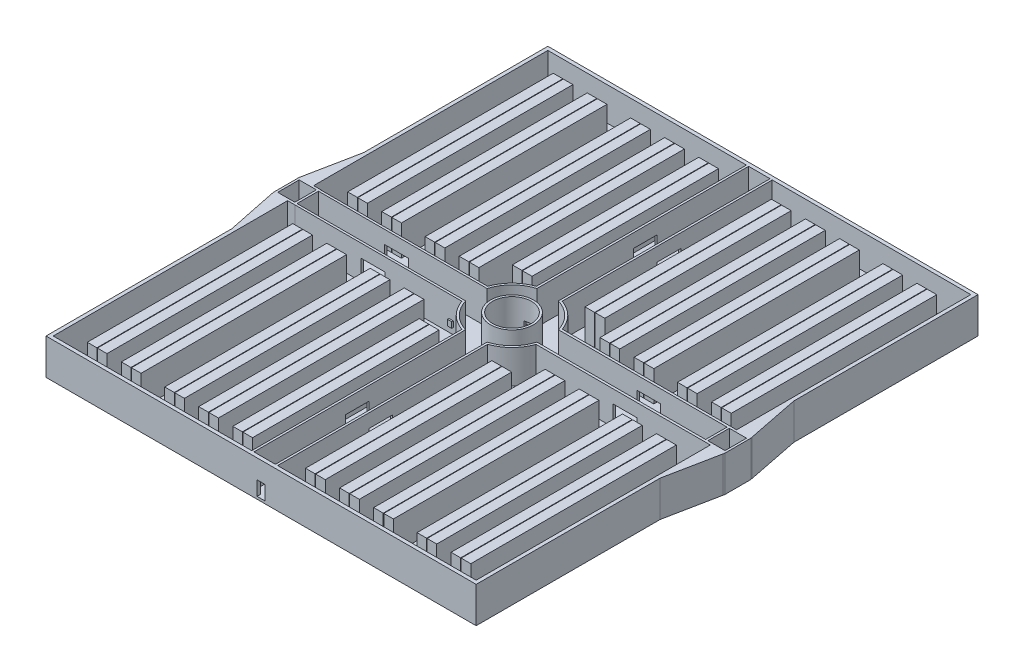
from build123d import *

# Parameters (mm, degrees)
SKETCH2_W                 = 60000
SKETCH2_H                 = 70000
BOSS_EXTRUDE1_DEPTH       = 350
SKETCH3_R                 = 3000
CUT_EXTRUDE1_DEPTH        = 1
CUT_EXTRUDE1_DEPTH_BACK   = 351
BOSS_EXTRUDE2_DEPTH       = 4650
CUT_EXTRUDE2_START        = -31801
CUT_EXTRUDE2_DEPTH        = 60002
CUT_EXTRUDE3_START        = -36801
CUT_EXTRUDE3_DEPTH        = 70002
SKETCH9_W                 = 60000
SKETCH9_H                 = 70000
SKETCH9_W_2               = 59000
SKETCH9_H_2               = 69000
BOSS_EXTRUDE3_DEPTH       = 4650
CUT_EXTRUDE4_DEPTH        = 1
CUT_EXTRUDE4_DEPTH_BACK   = 70001
SKETCH12_W                = 1337.685506768
SKETCH12_H                = 28664.780813437
SKETCH12_W_2              = 1337.314493232
BOSS_EXTRUDE5_DEPTH       = 4270
SKETCH13_R                = 3000
SKETCH13_R_2              = 2700
BOSS_EXTRUDE6_DEPTH       = 5000
BOSS_EXTRUDE6_DEPTH_BACK  = 1000
CUT_EXTRUDE6_DEPTH        = 60000
SKETCH16_W                = 1340
SKETCH16_H                = 26000
BOSS_EXTRUDE7_DEPTH       = 4270
MIRROR4_COPY_1_SKETCH_W   = 1337.685506768
MIRROR4_COPY_1_SKETCH_H   = 28664.780813437
MIRROR4_COPY_1_SKETCH_W_2 = 1337.314493232
MIRROR4_COPY_1_DEPTH      = 4270
MIRROR5_COPY_1_SKETCH_W   = 1337.685506768
MIRROR5_COPY_1_SKETCH_H   = 28664.780813437
MIRROR5_COPY_1_SKETCH_W_2 = 1337.314493232
MIRROR5_COPY_1_DEPTH      = 4270
MIRROR5_COPY_2_SKETCH_W   = 1340
MIRROR5_COPY_2_SKETCH_H   = 26000
MIRROR5_COPY_2_DEPTH      = 4270
MIRROR5_COPY_3_SKETCH_W   = 1337.685506768
MIRROR5_COPY_3_SKETCH_H   = 28664.780813437
MIRROR5_COPY_3_SKETCH_W_2 = 1337.314493232
MIRROR5_COPY_3_DEPTH      = 4270
MIRROR5_COPY_4_SKETCH_W   = 1337.685506768
MIRROR5_COPY_4_SKETCH_H   = 28664.780813437
MIRROR5_COPY_4_SKETCH_W_2 = 1337.314493232
MIRROR5_COPY_4_DEPTH      = 4270
BOSS_EXTRUDE12_START      = -350
BOSS_EXTRUDE12_DEPTH      = 5000
SKETCH26_W                = 600
SKETCH26_H                = 800
BOSS_EXTRUDE14_DEPTH      = 220
MIRROR15_COPY_1_SKETCH_W  = 600
MIRROR15_COPY_1_SKETCH_H  = 800
MIRROR15_COPY_1_DEPTH     = 220
MIRROR15_COPY_2_SKETCH_W  = 600
MIRROR15_COPY_2_SKETCH_H  = 800
MIRROR15_COPY_2_DEPTH     = 220
SKETCH20_W                = 2400
SKETCH20_H                = 3000
CUT_EXTRUDE7_DEPTH        = 4650
CUT_EXTRUDE9_DEPTH        = 400


with BuildPart() as part:
    # Sketch2 → Boss-Extrude1 (new body)
    with BuildSketch(Plane(origin=(0, 0, 0), x_dir=(1, 0, 0), z_dir=(0, 1, 0))):
        Rectangle(SKETCH2_W, SKETCH2_H)
    extrude(amount=BOSS_EXTRUDE1_DEPTH)

    # Sketch3 → Cut-Extrude1 (cut, two sides)
    with BuildSketch(Plane(origin=(0, 350, 0), x_dir=(1, 0, 0), z_dir=(0, 1, 0))) as cut_extrude1_sk:
        Circle(SKETCH3_R)
    extrude(amount=CUT_EXTRUDE1_DEPTH, mode=Mode.SUBTRACT)
    extrude(cut_extrude1_sk.sketch, amount=-CUT_EXTRUDE1_DEPTH_BACK, mode=Mode.SUBTRACT)

    # Sketch4 → Boss-Extrude2 (add)
    with BuildSketch(Plane(origin=(0, 350, 0), x_dir=(1, 0, 0), z_dir=(0, 1, 0))):
        with BuildLine():
            Line((-30000, 1495.711965542), (-30000, 1795.711965542))
            Line((-30000, 1795.711965542), (-5198.597747163, 1795.711965542))
            ThreePointArc((-5198.597747163, 1795.711965542), (-3890.6911404, 3887.48279096), (-1800, 5197.114584075))
            Line((-1800, 5197.114584075), (-1800, 35000))
            Line((-1800, 35000), (-1500, 35000))
            Line((-1500, 35000), (-1500, 4978.955713802))
            ThreePointArc((-1500, 4978.955713802), (-3678.538071342, 3675.371771357), (-4980.245547775, 1495.711965542))
            Line((-4980.245547775, 1495.711965542), (-5292.716289027, 1495.711965542))
            Line((-5292.716289027, 1495.711965542), (-30000, 1495.711965542))
        make_face()
        with BuildLine():
            Line((-30000, -1500), (-4978.955713802, -1500))
            ThreePointArc((-4978.955713802, -1500), (-3676.95526217, -3676.95526217), (-1500, -4978.955713802))
            Line((-1500, -4978.955713802), (-1500, -35000))
            Line((-1500, -35000), (-1800, -35000))
            Line((-1800, -35000), (-1800, -5197.114584075))
            ThreePointArc((-1800, -5197.114584075), (-3889.087296526, -3889.087296526), (-5197.114584075, -1800))
            Line((-5197.114584075, -1800), (-30000, -1800))
            Line((-30000, -1800), (-30000, -1500))
        make_face()
        with BuildLine():
            Line((30000, 1495.711965542), (30000, 1830.438373126))
            Line((30000, 1830.438373126), (5186.472342758, 1830.438373126))
            ThreePointArc((5186.472342758, 1830.438373126), (3877.670193089, 3900.470981001), (1800, 5197.114584075))
            Line((1800, 5197.114584075), (1800, 35000))
            Line((1800, 35000), (1500, 35000))
            Line((1500, 35000), (1500, 4978.955713802))
            ThreePointArc((1500, 4978.955713802), (3678.538071342, 3675.371771357), (4980.245547775, 1495.711965542))
            Line((4980.245547775, 1495.711965542), (30000, 1495.711965542))
        make_face()
        with BuildLine():
            Line((4978.955713802, -1500), (30000, -1500))
            Line((30000, -1500), (30000, -1800))
            Line((30000, -1800), (5197.114584075, -1800))
            ThreePointArc((5197.114584075, -1800), (3889.087296526, -3889.087296526), (1800, -5197.114584075))
            Line((1800, -5197.114584075), (1800, -35000))
            Line((1800, -35000), (1500, -35000))
            Line((1500, -35000), (1500, -4978.955713802))
            ThreePointArc((1500, -4978.955713802), (3676.95526217, -3676.95526217), (4978.955713802, -1500))
        make_face()
    extrude(amount=BOSS_EXTRUDE2_DEPTH)

    # Sketch6 → Cut-Extrude2 (cut)
    with BuildSketch(Plane.ZY.offset(1800).offset(CUT_EXTRUDE2_START)):
        Polygon((20098.557292037, 350), (21748.557292037, 350), (21748.557292037, 3100), (20098.557292037, 3100), (18448.557292037, 3100), (18448.557292037, 350), align=None)
    cut_extrude2 = extrude(amount=CUT_EXTRUDE2_DEPTH, mode=Mode.SUBTRACT)

    # Mirror1: Cut-Extrude2 across plane
    add(cut_extrude2.mirror(Plane(origin=(0, 0, 0), x_dir=(1, 0, 0), z_dir=(0, 0, -1))), mode=Mode.SUBTRACT)

    # Sketch7 → Cut-Extrude3 (cut)
    with BuildSketch(Plane.XY.offset(1800).offset(CUT_EXTRUDE3_START)):
        Polygon((-17598.557292037, 350), (-15948.557292037, 350), (-15948.557292037, 3170.045761237), (-17598.557292037, 3170.045761237), (-19248.557292037, 3170.045761237), (-19248.557292037, 350), align=None)
    cut_extrude3 = extrude(amount=CUT_EXTRUDE3_DEPTH, mode=Mode.SUBTRACT)

    # Mirror2: Cut-Extrude3 across plane
    add(cut_extrude3.mirror(Plane.ZY), mode=Mode.SUBTRACT)

    # Sketch9 → Boss-Extrude3 (add)
    with BuildSketch(Plane(origin=(0, 350, 0), x_dir=(1, 0, 0), z_dir=(0, 1, 0))):
        Rectangle(SKETCH9_W, SKETCH9_H)
        Rectangle(SKETCH9_W_2, SKETCH9_H_2, mode=Mode.SUBTRACT)
    extrude(amount=BOSS_EXTRUDE3_DEPTH)

    # Sketch11 → Cut-Extrude4 (cut, two sides)
    with BuildSketch(Plane.XY.offset(35000)) as cut_extrude4_sk:
        Polygon((550, 2345.832597599), (550, 2000), (550, 350), (-550, 350), (-550, 2000), (-550, 2345.832597599), align=None)
    extrude(amount=CUT_EXTRUDE4_DEPTH, mode=Mode.SUBTRACT)
    extrude(cut_extrude4_sk.sketch, amount=-CUT_EXTRUDE4_DEPTH_BACK, mode=Mode.SUBTRACT)

    # Sketch12 → Boss-Extrude5 (add)
    with BuildSketch(Plane(origin=(0, 350, 0), x_dir=(1, 0, 0), z_dir=(0, 1, 0))):
        with Locations((21329.714538653, 18162.828779845)):
            Rectangle(SKETCH12_W, SKETCH12_H)
        with Locations((19917.214538653, 18162.828779845)):
            Rectangle(SKETCH12_W_2, SKETCH12_H)
        Polygon((25411.057292037, 3830.438373126), (25411.057292037, 32495.219186563), (26748.557292037, 32495.219186563), (26748.557292037, 18184.780561825), (26748.557292037, 3830.438373126), align=None)
        Polygon((25336.057292037, 3830.438373126), (25336.057292037, 32495.219186563), (25160, 32495.219186563), (25090, 32495.219186563), (23998.557292037, 32495.219186563), (23998.557292037, 18165.219186563), (23998.557292037, 3830.438373126), (25090, 3830.438373126), (25102.109097724, 3830.438373126), (25160, 3830.438373126), align=None)
    boss_extrude5 = extrude(amount=BOSS_EXTRUDE5_DEPTH)

    # Mirror3: Boss-Extrude5 across plane
    add(boss_extrude5.mirror(Plane.ZY.offset(-17598.557292037)))

    # Sketch13 → Boss-Extrude6 (add, two sides)
    with BuildSketch(Plane(origin=(0, 350, 0), x_dir=(1, 0, 0), z_dir=(0, 1, 0))) as boss_extrude6_sk:
        Circle(SKETCH13_R)
        Circle(SKETCH13_R_2, mode=Mode.SUBTRACT)
    extrude(amount=BOSS_EXTRUDE6_DEPTH)
    extrude(boss_extrude6_sk.sketch, amount=-BOSS_EXTRUDE6_DEPTH_BACK)

    # Sketch15 → Cut-Extrude6 (cut)
    with BuildSketch(Plane(origin=(0, 0, 34500), x_dir=(-1, 0, 0), z_dir=(0, 0, -1))):
        Polygon((0, 350), (900, 350), (900, 2345.832597599), (900, 2600), (0, 2600), (-900, 2600), (-900, 350), align=None)
    extrude(amount=CUT_EXTRUDE6_DEPTH, mode=Mode.SUBTRACT)

    # Sketch16 → Boss-Extrude7 (add)
    with BuildSketch(Plane(origin=(0, 350, 0), x_dir=(1, 0, 0), z_dir=(0, 1, 0))):
        with Locations((5778.557292037, 19495.219186563)):
            Rectangle(SKETCH16_W, SKETCH16_H)
        with Locations((4363.557292037, 19495.219186563)):
            Rectangle(SKETCH16_W, SKETCH16_H)
    boss_extrude7 = extrude(amount=BOSS_EXTRUDE7_DEPTH)

    # Mirror4: Boss-Extrude7, Boss-Extrude5 across plane
    add(boss_extrude7.mirror(Plane.ZY))
    add(boss_extrude5.mirror(Plane.ZY))

    # Mirror4 copy 1 sketch → Mirror4 copy 1 (add)
    with BuildSketch(Plane(origin=(-35197.114584075, 350, 0), x_dir=(1, 0, 0), z_dir=(0, 1, 0))):
        with Locations((21329.714538653, 18162.828779845)):
            Rectangle(MIRROR4_COPY_1_SKETCH_W, MIRROR4_COPY_1_SKETCH_H)
        with Locations((19917.214538653, 18162.828779845)):
            Rectangle(MIRROR4_COPY_1_SKETCH_W_2, MIRROR4_COPY_1_SKETCH_H)
        Polygon((25411.057292037, 3830.438373126), (25411.057292037, 32495.219186563), (26748.557292037, 32495.219186563), (26748.557292037, 18184.780561825), (26748.557292037, 3830.438373126), align=None)
        Polygon((25336.057292037, 3830.438373126), (25336.057292037, 32495.219186563), (25160, 32495.219186563), (25090, 32495.219186563), (23998.557292037, 32495.219186563), (23998.557292037, 18165.219186563), (23998.557292037, 3830.438373126), (25090, 3830.438373126), (25102.109097724, 3830.438373126), (25160, 3830.438373126), align=None)
    extrude(amount=MIRROR4_COPY_1_DEPTH)

    # Mirror5: Boss-Extrude5, Boss-Extrude7 across plane
    add(boss_extrude5.mirror(Plane(origin=(0, 0, 0), x_dir=(1, 0, 0), z_dir=(0, 0, -1))))
    add(boss_extrude7.mirror(Plane(origin=(0, 0, 0), x_dir=(1, 0, 0), z_dir=(0, 0, -1))))

    # Mirror5 copy 1 sketch → Mirror5 copy 1 (add)
    with BuildSketch(Plane(origin=(35197.114584075, 350, 0), x_dir=(-1, 0, 0), z_dir=(0, 1, 0))):
        with Locations((21329.714538653, 18162.828779845)):
            Rectangle(MIRROR5_COPY_1_SKETCH_W, MIRROR5_COPY_1_SKETCH_H)
        with Locations((19917.214538653, 18162.828779845)):
            Rectangle(MIRROR5_COPY_1_SKETCH_W_2, MIRROR5_COPY_1_SKETCH_H)
        Polygon((25411.057292037, 3830.438373126), (25411.057292037, 32495.219186563), (26748.557292037, 32495.219186563), (26748.557292037, 18184.780561825), (26748.557292037, 3830.438373126), align=None)
        Polygon((25336.057292037, 3830.438373126), (25336.057292037, 32495.219186563), (25160, 32495.219186563), (25090, 32495.219186563), (23998.557292037, 32495.219186563), (23998.557292037, 18165.219186563), (23998.557292037, 3830.438373126), (25090, 3830.438373126), (25102.109097724, 3830.438373126), (25160, 3830.438373126), align=None)
    extrude(amount=MIRROR5_COPY_1_DEPTH)

    # Mirror5 copy 2 sketch → Mirror5 copy 2 (add)
    with BuildSketch(Plane(origin=(0, 350, 0), x_dir=(-1, 0, 0), z_dir=(0, 1, 0))):
        with Locations((5778.557292037, 19495.219186563)):
            Rectangle(MIRROR5_COPY_2_SKETCH_W, MIRROR5_COPY_2_SKETCH_H)
        with Locations((4363.557292037, 19495.219186563)):
            Rectangle(MIRROR5_COPY_2_SKETCH_W, MIRROR5_COPY_2_SKETCH_H)
    extrude(amount=MIRROR5_COPY_2_DEPTH)

    # Mirror5 copy 3 sketch → Mirror5 copy 3 (add)
    with BuildSketch(Plane(origin=(0, 350, 0), x_dir=(-1, 0, 0), z_dir=(0, 1, 0))):
        with Locations((21329.714538653, 18162.828779845)):
            Rectangle(MIRROR5_COPY_3_SKETCH_W, MIRROR5_COPY_3_SKETCH_H)
        with Locations((19917.214538653, 18162.828779845)):
            Rectangle(MIRROR5_COPY_3_SKETCH_W_2, MIRROR5_COPY_3_SKETCH_H)
        Polygon((25411.057292037, 3830.438373126), (25411.057292037, 32495.219186563), (26748.557292037, 32495.219186563), (26748.557292037, 18184.780561825), (26748.557292037, 3830.438373126), align=None)
        Polygon((25336.057292037, 3830.438373126), (25336.057292037, 32495.219186563), (25160, 32495.219186563), (25090, 32495.219186563), (23998.557292037, 32495.219186563), (23998.557292037, 18165.219186563), (23998.557292037, 3830.438373126), (25090, 3830.438373126), (25102.109097724, 3830.438373126), (25160, 3830.438373126), align=None)
    extrude(amount=MIRROR5_COPY_3_DEPTH)

    # Mirror5 copy 4 sketch → Mirror5 copy 4 (add)
    with BuildSketch(Plane(origin=(-35197.114584075, 350, 0), x_dir=(1, 0, 0), z_dir=(0, 1, 0))):
        with Locations((21329.714538653, -18162.828779845)):
            Rectangle(MIRROR5_COPY_4_SKETCH_W, MIRROR5_COPY_4_SKETCH_H)
        with Locations((19917.214538653, -18162.828779845)):
            Rectangle(MIRROR5_COPY_4_SKETCH_W_2, MIRROR5_COPY_4_SKETCH_H)
        Polygon((25411.057292037, -3830.438373126), (25411.057292037, -32495.219186563), (26748.557292037, -32495.219186563), (26748.557292037, -18184.780561825), (26748.557292037, -3830.438373126), align=None)
        Polygon((25336.057292037, -3830.438373126), (25336.057292037, -32495.219186563), (25160, -32495.219186563), (25090, -32495.219186563), (23998.557292037, -32495.219186563), (23998.557292037, -18165.219186563), (23998.557292037, -3830.438373126), (25090, -3830.438373126), (25102.109097724, -3830.438373126), (25160, -3830.438373126), align=None)
    extrude(amount=MIRROR5_COPY_4_DEPTH)

    # Sketch18 → Boss-Extrude12 (add)
    with BuildSketch(Plane(origin=(0, 350, 0), x_dir=(1, 0, 0), z_dir=(0, 1, 0)).offset(BOSS_EXTRUDE12_START)):
        Polygon((28500, -1500), (28500, 1495.711965542), (28500, 1795.711965542), (28500, 1830.438373126), (29500, 1830.438373126), (29500, 11830.438373126), (31500, 1795.711965542), (31500, 1495.711965542), (31500, -1500), (31500, -1804.092700607), (29500, -11500), (29500, -1801.364233536), (28500, -1800), align=None)
    boss_extrude12 = extrude(amount=BOSS_EXTRUDE12_DEPTH)

    # Sketch26 → Boss-Extrude14 (add)
    with BuildSketch(Plane.XY.offset(1800)):
        with Locations((-6694.701361114, 1630.664480551)):
            Rectangle(SKETCH26_W, SKETCH26_H)
    boss_extrude14 = extrude(amount=BOSS_EXTRUDE14_DEPTH)

    # Mirror9: part across plane


with BuildPart() as part_1:
    add(part.part)
    add(part.part.mirror(Plane(origin=(0, 0, 0), x_dir=(1, 0, 0), z_dir=(0, 0, -1))))

    # Mirror14: Boss-Extrude14 across plane
    add(boss_extrude14.mirror(Plane.ZY))

    # Mirror15 copy 1 sketch → Mirror15 copy 1 (add)
    with BuildSketch(Plane(origin=(0, 0, -1800), x_dir=(-1, 0, 0), z_dir=(0, 0, -1))):
        with Locations((-6694.701361114, 1630.664480551)):
            Rectangle(MIRROR15_COPY_1_SKETCH_W, MIRROR15_COPY_1_SKETCH_H)
    extrude(amount=MIRROR15_COPY_1_DEPTH)

    # Mirror15 copy 2 sketch → Mirror15 copy 2 (add)
    with BuildSketch(Plane(origin=(0, 0, -1800), x_dir=(1, 0, 0), z_dir=(0, 0, -1))):
        with Locations((-6694.701361114, -1630.664480551)):
            Rectangle(MIRROR15_COPY_2_SKETCH_W, MIRROR15_COPY_2_SKETCH_H)
    extrude(amount=MIRROR15_COPY_2_DEPTH)

    # Sketch20 → Cut-Extrude7 (cut)
    with BuildSketch(Plane(origin=(0, 5000, 0), x_dir=(1, 0, 0), z_dir=(0, 1, 0))):
        with Locations((30000, 13.172836259)):
            Rectangle(SKETCH20_W, SKETCH20_H)
    cut_extrude7 = extrude(amount=-CUT_EXTRUDE7_DEPTH, mode=Mode.SUBTRACT)

    # Mirror16: Boss-Extrude12, Cut-Extrude7 across plane
    add(boss_extrude12.mirror(Plane.ZY))
    add(cut_extrude7.mirror(Plane.ZY), mode=Mode.SUBTRACT)

    # Sketch27 → Cut-Extrude9 (cut)
    with BuildSketch(Plane.ZY.offset(-28500)):
        Polygon((0, 350), (600, 350), (600, 2650), (0, 2650), (-600, 2650), (-600, 373.78125369), (-600, 350), align=None)
    cut_extrude9 = extrude(amount=-CUT_EXTRUDE9_DEPTH, mode=Mode.SUBTRACT)

    # Mirror17: Cut-Extrude9 across plane
    add(cut_extrude9.mirror(Plane.ZY), mode=Mode.SUBTRACT)


solid = part_1.part
